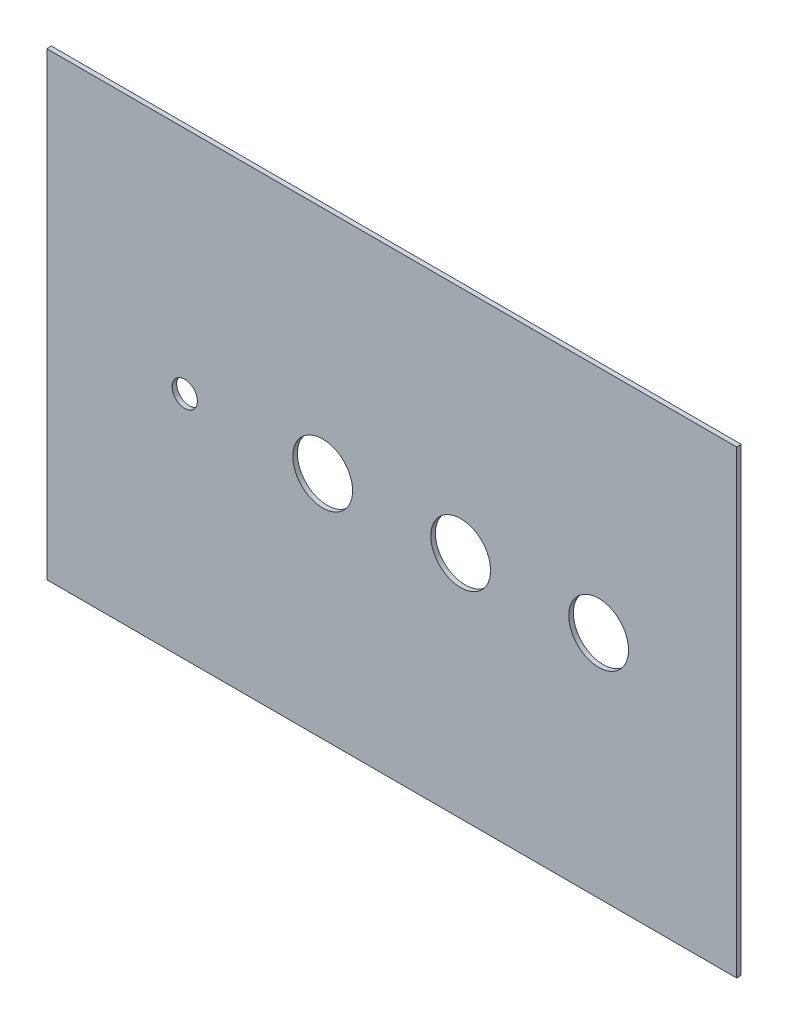
from build123d import *

# Parameters (mm, degrees)
SKETCH1_W           = 300
SKETCH1_H           = 200
SKETCH1_R           = 13
SKETCH1_R_2         = 5.5
BOSS_EXTRUDE1_DEPTH = 2


with BuildPart() as part:
    # Sketch1 → Boss-Extrude1 (new body)
    with BuildSketch(Plane.XY):
        Rectangle(SKETCH1_W, SKETCH1_H)
        with Locations((30, 0)):
            Circle(SKETCH1_R, mode=Mode.SUBTRACT)
        with Locations((90, 0)):
            Circle(SKETCH1_R, mode=Mode.SUBTRACT)
        with Locations((-30, 0)):
            Circle(SKETCH1_R, mode=Mode.SUBTRACT)
        with Locations((-90, 0)):
            Circle(SKETCH1_R_2, mode=Mode.SUBTRACT)
    extrude(amount=BOSS_EXTRUDE1_DEPTH)


solid = part.part
